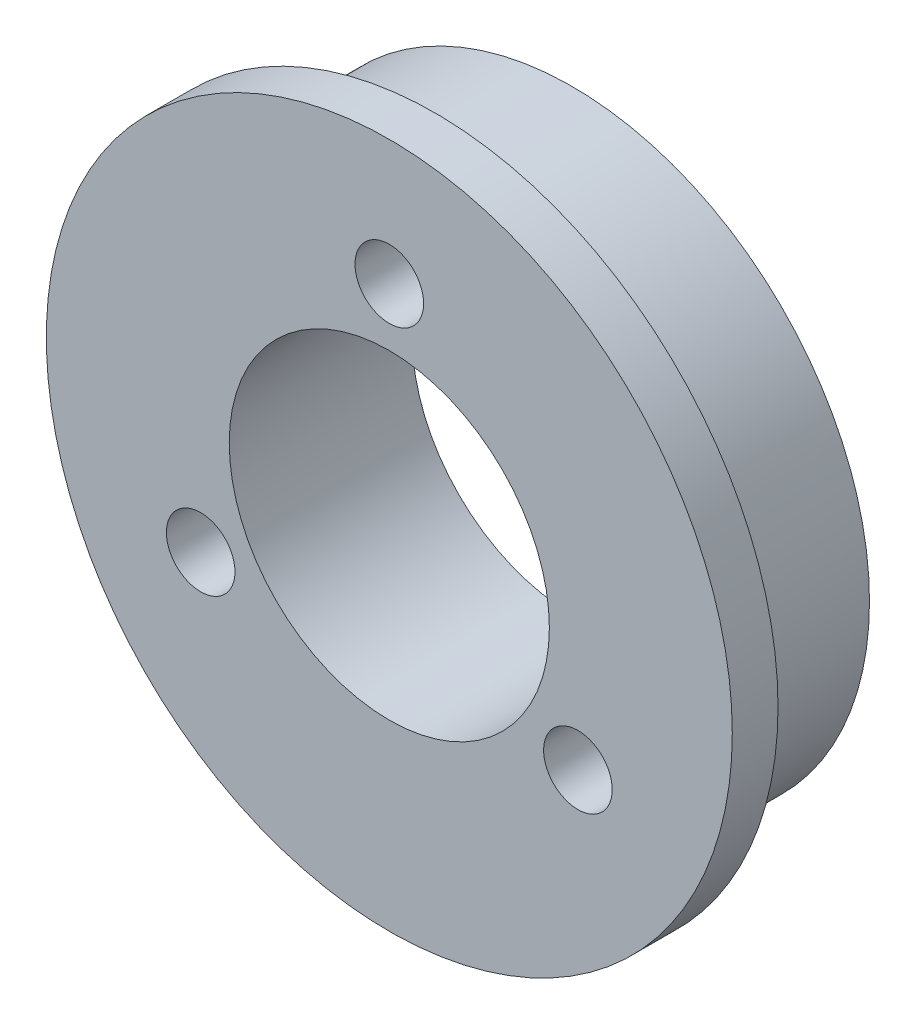
from build123d import *

# Parameters (mm, degrees)
SKETCH1_R           = 13
SKETCH1_R_2         = 7
BOSS_EXTRUDE1_DEPTH = 6
SKETCH2_R           = 15
SKETCH2_R_2         = 7
BOSS_EXTRUDE2_DEPTH = 2
SKETCH3_R           = 1.5
CUT_EXTRUDE1_DEPTH  = 16


with BuildPart() as part:
    # Sketch1 → Boss-Extrude1 (new body)
    with BuildSketch(Plane.XY):
        Circle(SKETCH1_R)
        Circle(SKETCH1_R_2, mode=Mode.SUBTRACT)
    extrude(amount=BOSS_EXTRUDE1_DEPTH)

    # Sketch2 → Boss-Extrude2 (add)
    with BuildSketch(Plane.XY.offset(6)):
        Circle(SKETCH2_R)
        Circle(SKETCH2_R_2, mode=Mode.SUBTRACT)
    extrude(amount=BOSS_EXTRUDE2_DEPTH)

    # Sketch3 → Cut-Extrude1 (cut)
    with BuildSketch(Plane.XY.offset(8)):
        with Locations((0, 9.525)):
            Circle(SKETCH3_R)
        with Locations((8.248891971, -4.7625)):
            Circle(SKETCH3_R)
        with Locations((-8.248891971, -4.7625)):
            Circle(SKETCH3_R)
    extrude(amount=-CUT_EXTRUDE1_DEPTH, mode=Mode.SUBTRACT)


solid = part.part
